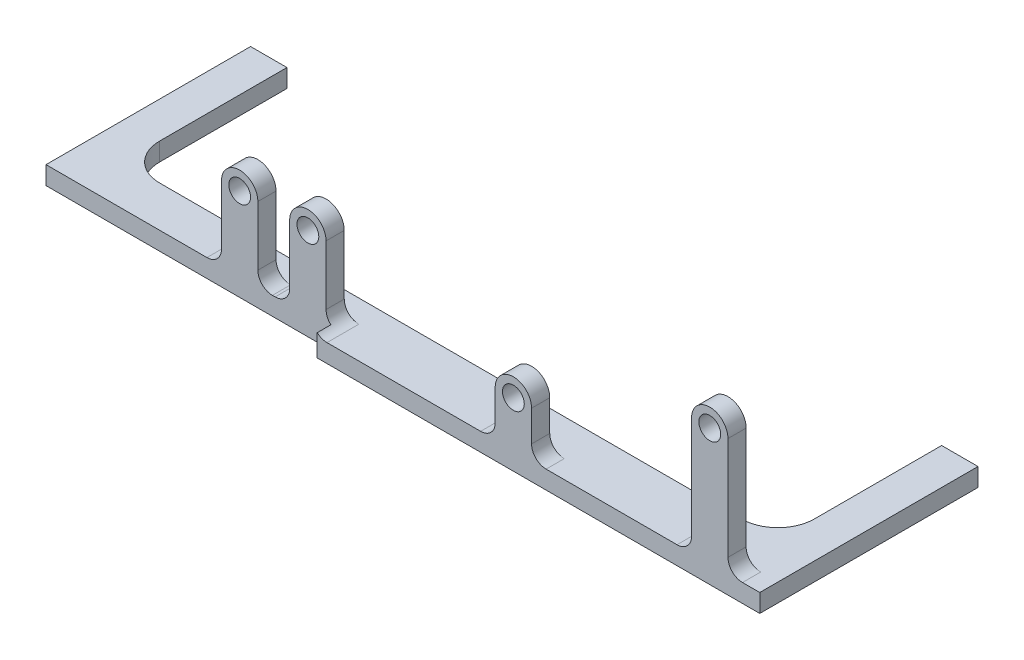
from build123d import *

# Parameters (mm, degrees)
BOSS_EXTRUDE1_DEPTH     = 40
SKETCH2_R               = 24
BOSS_EXTRUDE2_DEPTH     = 40
SKETCH3_R               = 24
BOSS_EXTRUDE3_DEPTH     = 40
SCALE1_SCALE            = 0.125
FILLET3_R               = 4
FILLET4_R               = 4
CUT_EXTRUDE1_DEPTH      = 38.275
CUT_EXTRUDE1_DEPTH_BACK = 6
SKETCH5_OUTSIDE_W       = 249.408
SKETCH5_OUTSIDE_H       = 169.408
CUT_EXTRUDE2_DEPTH      = 38.275
CUT_EXTRUDE2_DEPTH_BACK = 6
SKETCH7_R               = 1.5
CUT_EXTRUDE3_DEPTH      = 5


with BuildPart() as part:
    # Sketch1 → Boss-Extrude1 (new body)
    with BuildSketch(Plane(origin=(0, 0, 0), x_dir=(1, 0, 0), z_dir=(0, 1, 0))):
        Polygon((-173.422280891, 480), (-173.422280891, 450), (-800, 450), (-800, -450), (-173.422280891, -450), (-173.422280891, -480), (800, -480), (800, 480), align=None)
    extrude(amount=-BOSS_EXTRUDE1_DEPTH)

    # Sketch2 → Boss-Extrude2 (add)
    with BuildSketch(Plane.XY.offset(480)):
        with BuildLine():
            Line((218, 0), (298, 0))
            Line((298, 0), (298, 100))
            ThreePointArc((298, 100), (258, 140), (218, 100))
            Line((218, 100), (218, 0))
        make_face()
        with Locations((258, 100)):
            Circle(SKETCH2_R, mode=Mode.SUBTRACT)
        with BuildLine():
            Line((650, 258.2), (650, 0))
            Line((650, 0), (730, 0))
            Line((730, 0), (730, 258.2))
            ThreePointArc((730, 258.2), (690, 298.2), (650, 258.2))
        make_face()
        with Locations((690, 258.2)):
            Circle(SKETCH2_R, mode=Mode.SUBTRACT)
        Polygon((650, 0), (298, 0), (218, 0), (-173.422280891, 0), (-173.422280891, -40), (800, -40), (800, 0), (730, 0), align=None)
    extrude(amount=-BOSS_EXTRUDE2_DEPTH)

    # Mirror1: part across plane


with BuildPart() as part_1:
    add(part.part)
    add(part.part.mirror(Plane.XY))

    # Sketch3 → Boss-Extrude3 (add)
    with BuildSketch(Plane.XY.offset(450)):
        with BuildLine():
            Line((-414, 0), (-334, 0))
            Line((-334, 0), (-334, 162.7))
            ThreePointArc((-334, 162.7), (-374, 202.7), (-414, 162.7))
            Line((-414, 162.7), (-414, 0))
        make_face()
        with Locations((-374, 162.7)):
            Circle(SKETCH3_R, mode=Mode.SUBTRACT)
        with BuildLine():
            Line((-264, 0), (-184, 0))
            Line((-184, 0), (-184, 162.7))
            ThreePointArc((-184, 162.7), (-224, 202.7), (-264, 162.7))
            Line((-264, 162.7), (-264, 0))
        make_face()
        with Locations((-224, 162.7)):
            Circle(SKETCH3_R, mode=Mode.SUBTRACT)
    boss_extrude3 = extrude(amount=-BOSS_EXTRUDE3_DEPTH)

    # Mirror2: Boss-Extrude3 across plane
    add(boss_extrude3.mirror(Plane.XY))


with BuildPart() as part_2:
    # Scale1: scaled about (22.22402446, -11.339866564, 0)
    add(part_1.part.scale(SCALE1_SCALE).moved(Location((19.446021402, -9.922383243, 0))))

    # Fillet3
    fillet3_edges = [part_2.edges().sort_by_distance(p)[0] for p in [
        (-32.303978598, -9.922383243, 53.75),
        (-13.553978598, -9.922383243, 53.75),
        (-32.303978598, -9.922383243, -53.75),
        (-13.553978598, -9.922383243, -53.75),
        (46.696021403, -9.922383243, 57.5),
        (100.696021403, -9.922383243, 57.5),
        (100.696021403, -9.922383243, -57.5),
        (46.696021403, -9.922383243, -57.5),
    ]]
    fillet(fillet3_edges, radius=FILLET3_R)

    # Fillet4
    fillet4_edges = [part_2.edges().sort_by_distance(p)[0] for p in [
        (-3.553978598, -9.922383243, -53.75),
        (-22.303978598, -9.922383243, -53.75),
        (56.696021403, -9.922383243, -57.5),
        (110.696021402, -9.922383243, -57.5),
        (110.696021402, -9.922383243, 57.5),
        (56.696021403, -9.922383243, 57.5),
        (-3.553978598, -9.922383243, 53.75),
        (-22.303978598, -9.922383243, 53.75),
    ]]
    fillet(fillet4_edges, radius=FILLET4_R)

    # Sketch4 → Cut-Extrude1 (cut, two sides)
    with BuildSketch(Plane(origin=(0, -9.922383244, 0), x_dir=(1, 0, 0), z_dir=(0, 1, 0))) as cut_extrude1_sk:
        with BuildLine():
            Line((-60.553978598, 45), (99.446021402, 45))
            ThreePointArc((99.446021402, 45), (106.517089214, 42.071067812), (109.446021402, 35))
            Line((109.446021402, 35), (109.446021402, -35))
            ThreePointArc((109.446021402, -35), (106.517089214, -42.071067812), (99.446021402, -45))
            Line((99.446021402, -45), (-60.553978598, -45))
            ThreePointArc((-60.553978598, -45), (-67.62504641, -42.071067812), (-70.553978598, -35))
            Line((-70.553978598, -35), (-70.553978598, 35))
            ThreePointArc((-70.553978598, 35), (-67.62504641, 42.071067812), (-60.553978598, 45))
        make_face()
    extrude(amount=CUT_EXTRUDE1_DEPTH, mode=Mode.SUBTRACT)
    extrude(cut_extrude1_sk.sketch, amount=-CUT_EXTRUDE1_DEPTH_BACK, mode=Mode.SUBTRACT)

    # Sketch5 outside → Cut-Extrude2 (cut, two sides)
    with BuildSketch(Plane(origin=(0, -9.922383244, 0), x_dir=(1, 0, 0), z_dir=(0, 1, 0))) as cut_extrude2_sk:
        with Locations((19.446, 0)):
            Rectangle(SKETCH5_OUTSIDE_W, SKETCH5_OUTSIDE_H)
        Polygon((0, 0), (123.509842575, 0), (123.509842575, -66.212941814), (-94.641009198, -66.212941814), (-94.641009198, 0), align=None, mode=Mode.SUBTRACT)
    extrude(amount=CUT_EXTRUDE2_DEPTH, mode=Mode.SUBTRACT)
    extrude(cut_extrude2_sk.sketch, amount=-CUT_EXTRUDE2_DEPTH_BACK, mode=Mode.SUBTRACT)

    # Sketch7 → Cut-Extrude3 (cut)
    with BuildSketch(Plane(origin=(0, 0, 0), x_dir=(-1, 0, 0), z_dir=(0, 0, -1))):
        with Locations((-114.446021402, -12.422383244)):
            Circle(SKETCH7_R)
        with Locations((75.553978598, -12.422383244)):
            Circle(SKETCH7_R)
    extrude(amount=-CUT_EXTRUDE3_DEPTH, mode=Mode.SUBTRACT)


solid = part_2.part
